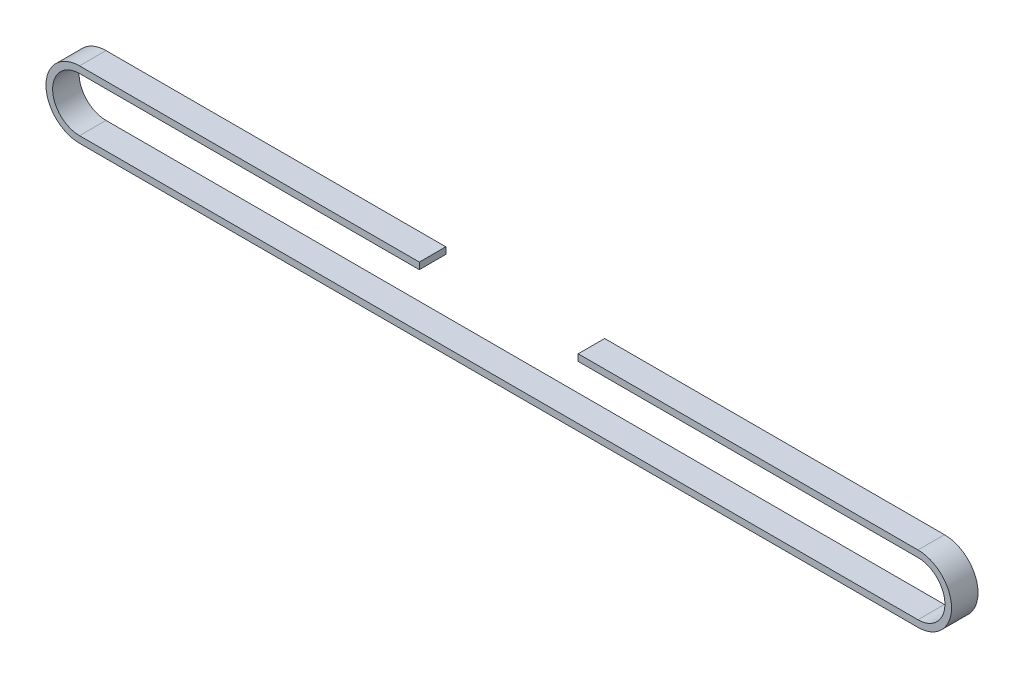
from build123d import *

# Parameters (mm, degrees)
AUFSATZ_LINEAR_AUSTRAGEN1_DEPTH = 3
SKIZZE2_W                       = 36
SKIZZE2_H                       = 1.5
SCHNITT_LINEAR_AUSTRAGEN1_DEPTH = 7


with BuildPart() as part:
    # Skizze1 → Aufsatz-Linear austragen1 (new body, symmetric)
    with BuildSketch(Plane.XY):
        with BuildLine():
            Line((-95, 7.6), (95, 7.6))
            ThreePointArc((95, 7.6), (102.6, 0), (95, -7.6))
            Line((95, -7.6), (-95, -7.6))
            ThreePointArc((-95, -7.6), (-102.6, 0), (-95, 7.6))
        make_face()
        with BuildLine():
            Line((-95, 6.1), (95, 6.1))
            ThreePointArc((95, 6.1), (101.1, 0), (95, -6.1))
            Line((95, -6.1), (-95, -6.1))
            ThreePointArc((-95, -6.1), (-101.1, 0), (-95, 6.1))
        make_face(mode=Mode.SUBTRACT)
    extrude(amount=AUFSATZ_LINEAR_AUSTRAGEN1_DEPTH, both=True)

    # Skizze2 → Schnitt-Linear austragen1 (cut, through all)
    with BuildSketch(Plane.XY.offset(3)):
        with Locations((0, 6.85)):
            Rectangle(SKIZZE2_W, SKIZZE2_H)
    extrude(amount=-SCHNITT_LINEAR_AUSTRAGEN1_DEPTH, mode=Mode.SUBTRACT)


solid = part.part
